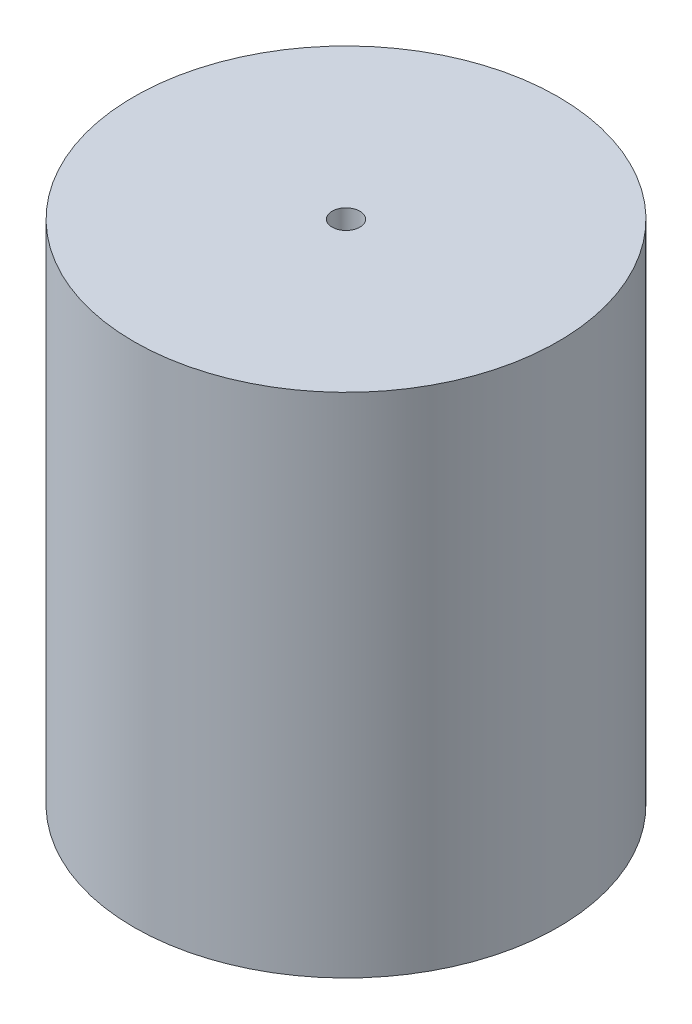
from build123d import *

# Parameters (mm, degrees)
SKETCH1_R           = 11.5
BOSS_EXTRUDE1_DEPTH = 27.5
SKETCH2_R           = 0.7525
CUT_EXTRUDE1_DEPTH  = 5


with BuildPart() as part:
    # Sketch1 → Boss-Extrude1 (new body)
    with BuildSketch(Plane(origin=(0, 0, 0), x_dir=(1, 0, 0), z_dir=(0, 1, 0))):
        Circle(SKETCH1_R)
    extrude(amount=BOSS_EXTRUDE1_DEPTH)

    # Sketch2 → Cut-Extrude1 (cut)
    with BuildSketch(Plane(origin=(0, 27.5, 0), x_dir=(1, 0, 0), z_dir=(0, 1, 0))):
        Circle(SKETCH2_R)
    extrude(amount=-CUT_EXTRUDE1_DEPTH, mode=Mode.SUBTRACT)


solid = part.part
